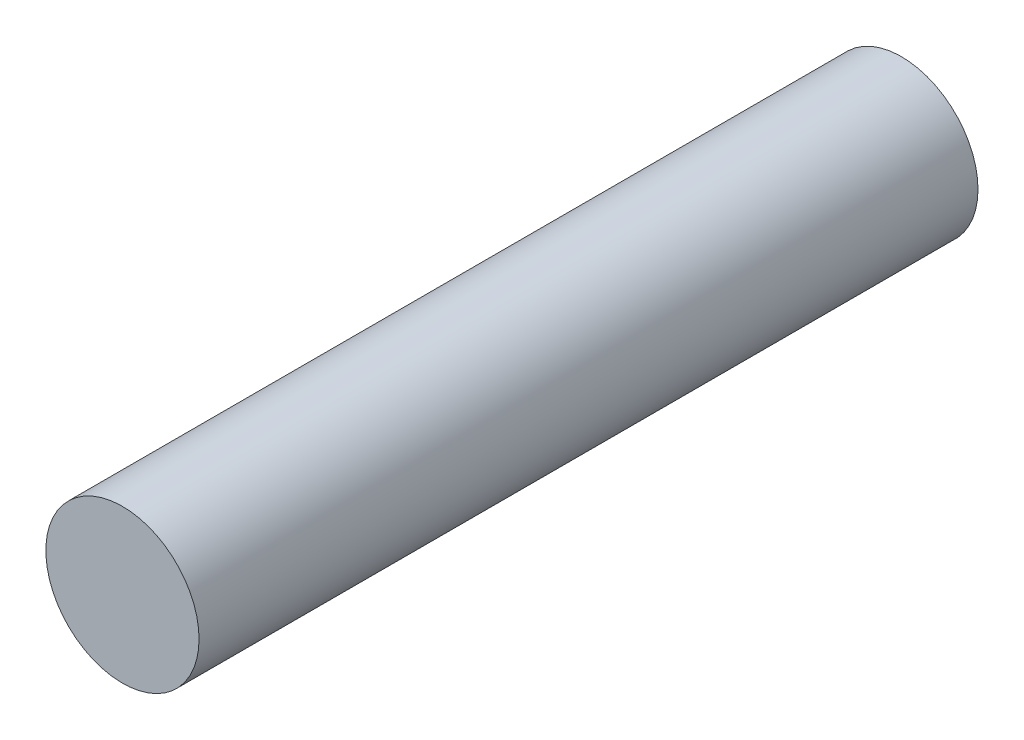
from build123d import *

# Parameters (mm, degrees)
SKETCH1_R           = 2.95
BOSS_EXTRUDE1_DEPTH = 30
CUT_EXTRUDE1_DEPTH  = 7


with BuildPart() as part:
    # Sketch1 → Boss-Extrude1 (new body)
    with BuildSketch(Plane.XY):
        Circle(SKETCH1_R)
    extrude(amount=BOSS_EXTRUDE1_DEPTH)

    # Sketch2 → Cut-Extrude1 (cut)
    with BuildSketch(Plane(origin=(0, 0, 0), x_dir=(-1, 0, 0), z_dir=(0, 0, -1))):
        with BuildLine():
            Line((-1.34969441, 1.435), (1.34969441, 1.435))
            ThreePointArc((1.34969441, 1.435), (0, -1.97), (-1.34969441, 1.435))
        make_face()
    extrude(amount=-CUT_EXTRUDE1_DEPTH, mode=Mode.SUBTRACT)


solid = part.part
